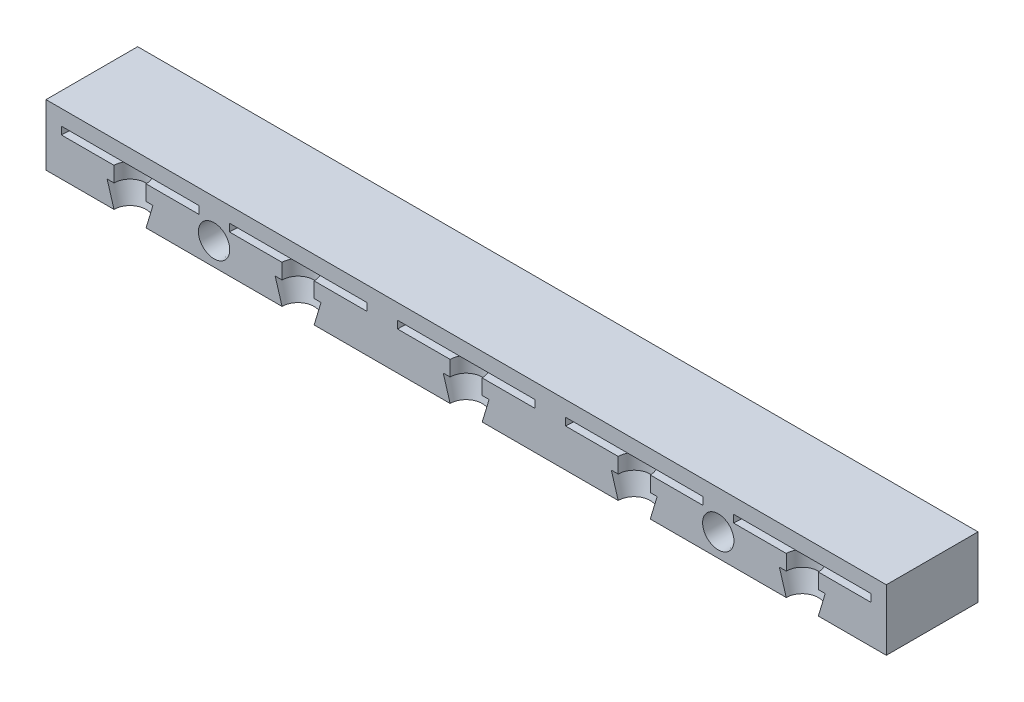
from build123d import *

# Parameters (mm, degrees)
SKETCH2_W           = 110
SKETCH2_H           = 8
BOSS_EXTRUDE1_DEPTH = 12
LPATTERN1_COUNT     = 5
LPATTERN1_PITCH     = 22
SKETCH4_R           = 2.05
CUT_EXTRUDE1_DEPTH  = 5
CUT_EXTRUDE1_TAPER  = 1


with BuildPart() as part:
    # Sketch2 → Boss-Extrude1 (new body)
    with BuildSketch(Plane.XY):
        with Locations((55, 4)):
            Rectangle(SKETCH2_W, SKETCH2_H)
    extrude(amount=-BOSS_EXTRUDE1_DEPTH)

    # Sketch3 → Cut-Revolve1 (revolve, cut)
    with BuildSketch(Plane.XY):
        Polygon((8, 3), (8.9, 3), (8.9, 5), (2, 5), (2, 6), (11, 6), (11, 0), (8.9, 0), align=None)
    cut_revolve1 = revolve(axis=Axis((11, 6, 0), (0, -1, 0)), mode=Mode.SUBTRACT)

    # LPattern1: Cut-Revolve1 ×5
    with Locations(*[(i * LPATTERN1_PITCH, 0, 0) for i in range(1, LPATTERN1_COUNT)]):
        add(cut_revolve1, mode=Mode.SUBTRACT)

    # Sketch4 → Cut-Extrude1 (cut)
    with BuildSketch(Plane.XY):
        with Locations((22, 3)):
            Circle(SKETCH4_R)
        with Locations((88, 3)):
            Circle(SKETCH4_R)
    extrude(amount=-CUT_EXTRUDE1_DEPTH, taper=CUT_EXTRUDE1_TAPER, mode=Mode.SUBTRACT)


solid = part.part
